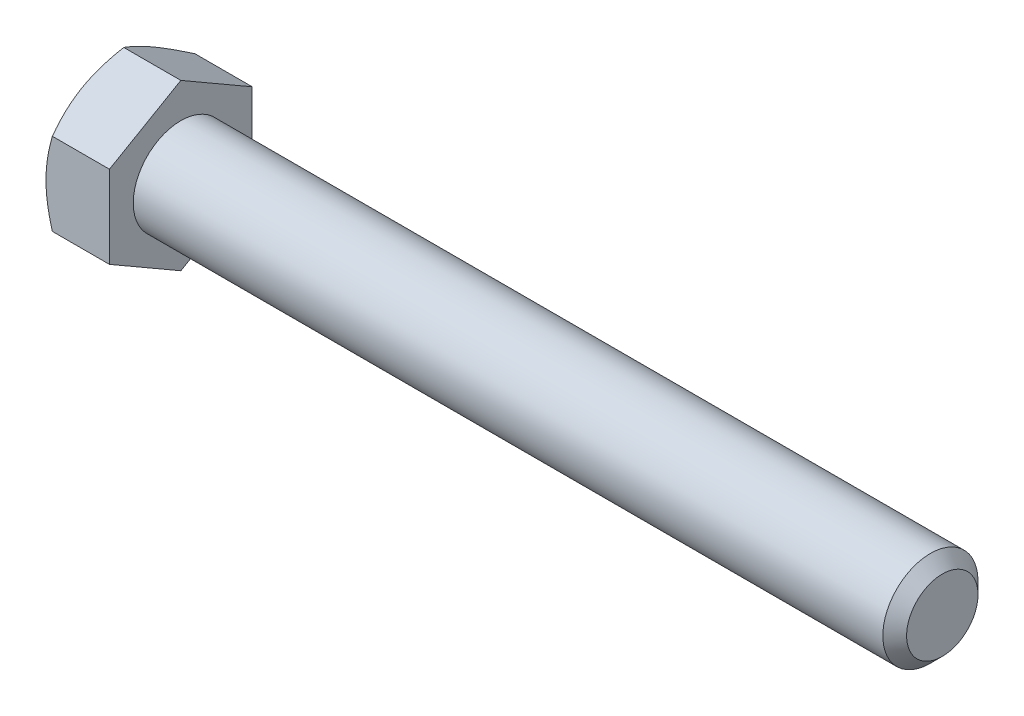
from build123d import *

# Parameters (mm, degrees)
SKETCH5_R           = 4.7625
BOSS_EXTRUDE3_DEPTH = 76.2
CHAMFER1_SIZE       = 1.190625
BOSS_EXTRUDE4_DEPTH = 6.35
SKETCH8_OUTSIDE_W   = 322.79
SKETCH8_OUTSIDE_H   = 325
SKETCH8_OUTSIDE_R   = 7.14375
CUT_EXTRUDE3_DEPTH  = 83.55
CUT_EXTRUDE3_TAPER  = 60


with BuildPart() as part:
    # Sketch5 → Boss-Extrude3 (new body)
    with BuildSketch(Plane(origin=(41.275, 0, 0), x_dir=(0, 0, -1), z_dir=(1, 0, 0))):
        Circle(SKETCH5_R)
    extrude(amount=-BOSS_EXTRUDE3_DEPTH)

    # Chamfer1
    chamfer1_edges = [part.edges().sort_by_distance(p)[0] for p in [
        (41.275, 0, 4.7625),
    ]]
    chamfer(chamfer1_edges, length=CHAMFER1_SIZE)

    # Sketch11 → Revolve1 (revolve)
    with BuildSketch(Plane.XY):
        Polygon((-34.925, 4.7625), (-34.925, 0), (20.6375, 0), (15.875, 4.7625), align=None)
    revolve(axis=Axis((-34.925, 0, 0), (1, 0, 0)))

    # Sketch6 → Boss-Extrude4 (add)
    with BuildSketch(Plane.ZY.offset(34.925)):
        Polygon((7.14375, 4.124445986), (0, 8.248891971), (-7.14375, 4.124445986), (-7.14375, -4.124445986), (0, -8.248891971), (7.14375, -4.124445986), align=None)
    extrude(amount=BOSS_EXTRUDE4_DEPTH)

    # Sketch8 outside → Cut-Extrude3 (cut, through all)
    with BuildSketch(Plane.ZY.offset(41.275)):
        Rectangle(SKETCH8_OUTSIDE_W, SKETCH8_OUTSIDE_H)
        Circle(SKETCH8_OUTSIDE_R, mode=Mode.SUBTRACT)
    extrude(amount=-CUT_EXTRUDE3_DEPTH, taper=CUT_EXTRUDE3_TAPER, mode=Mode.SUBTRACT)


solid = part.part
